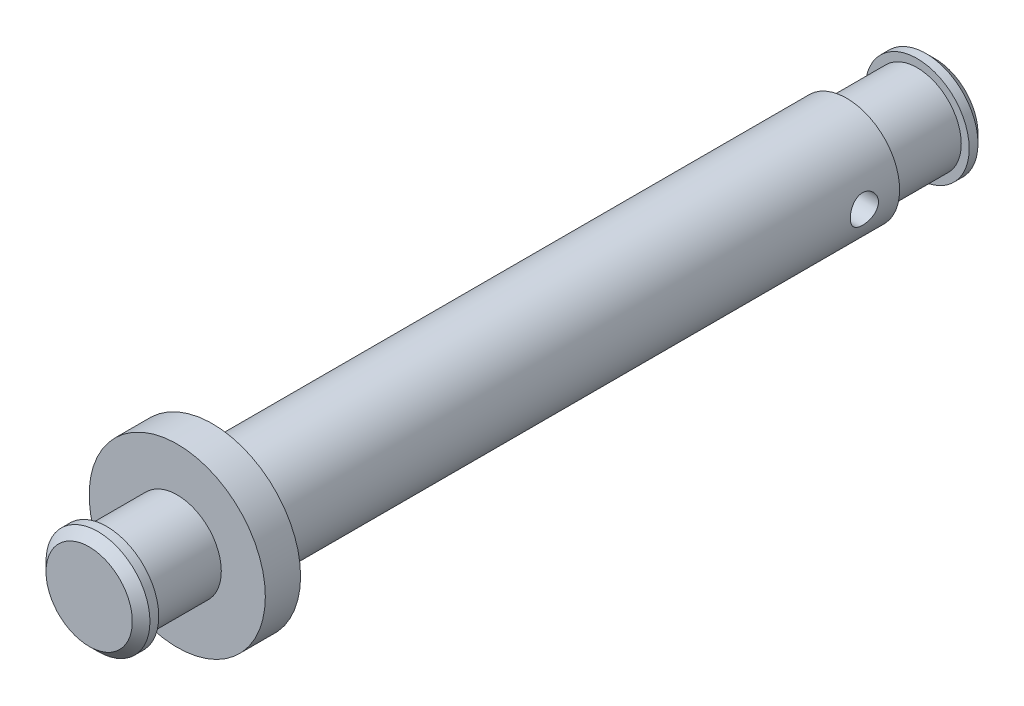
from build123d import *

# Parameters (mm, degrees)
SKETCH_2_R          = 0.8
CUT_EXTRUDE_1_DEPTH = 10
CHAMFER_1_SIZE      = 0.5


with BuildPart() as part:
    # Эскиз1 → Повернуть1 (revolve)
    with BuildSketch(Plane(origin=(0, 0, 0), x_dir=(0, 0, -1), z_dir=(1, 0, 0))):
        Polygon((0, 2.5), (0, 5), (2, 5), (2, 3), (38, 3), (38, 2.5), (42, 2.5), (42, 2.95), (43, 2.95), (43, 0), (0, 0), (-5, 0), (-5, 2.95), (-4, 2.95), (-4, 2.5), align=None)
    revolve(axis=Axis((0, 0, 0), (0, 0, -1)))

    # Эскиз2 → Вытянуть1 (cut, symmetric)
    with BuildSketch(Plane(origin=(0, 0, 0), x_dir=(0, 0, -1), z_dir=(1, 0, 0))):
        with Locations((36, 0)):
            Circle(SKETCH_2_R)
    extrude(amount=CUT_EXTRUDE_1_DEPTH, both=True, mode=Mode.SUBTRACT)

    # Фаска1
    chamfer_1_edges = [part.edges().sort_by_distance(p)[0] for p in [
        (0, -2.95, -43),
        (0, -2.95, 5),
    ]]
    chamfer(chamfer_1_edges, length=CHAMFER_1_SIZE)


solid = part.part
